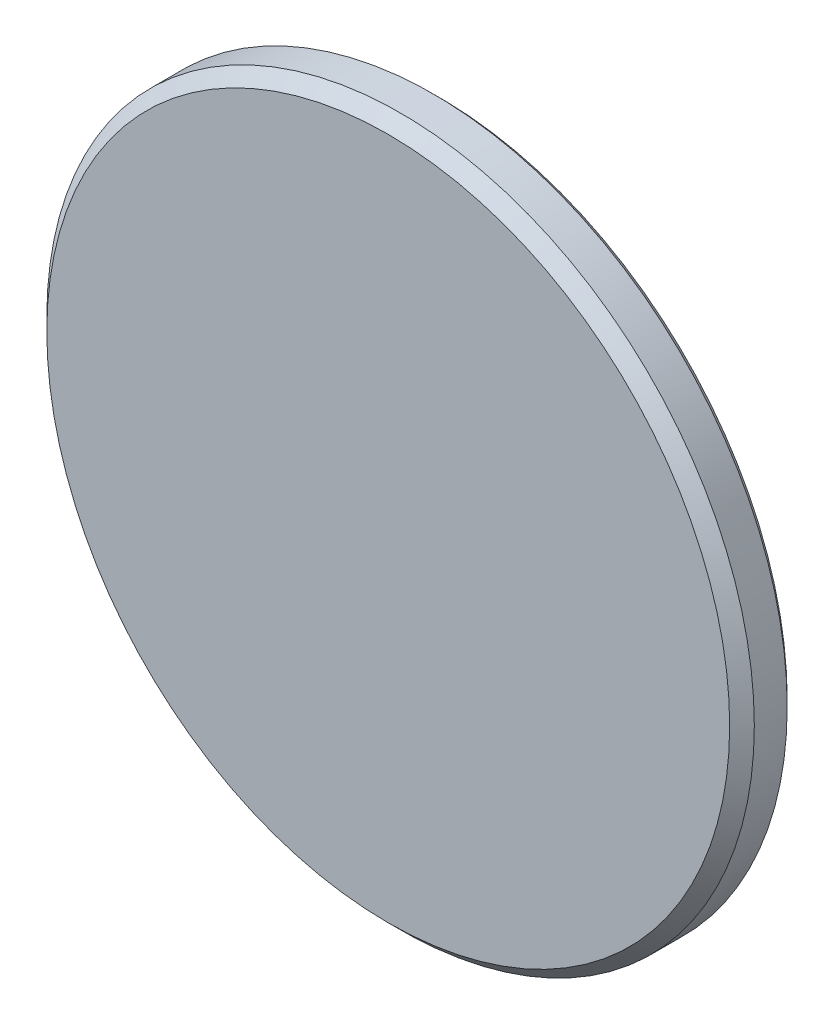
from build123d import *


with BuildPart() as part:
    # Sketch1 → Revolve1 (revolve)
    with BuildSketch(Plane(origin=(0, 0, 0), x_dir=(1, 0, 0), z_dir=(0, 1, 0))):
        Polygon((21.4884, 0), (0, 0), (0, -3.175), (21.1074, -3.175), (21.8694, -2.413), (21.8694, -0.381), align=None)
    revolve(axis=Axis((0, 0, 0), (0, 0, 1)))


solid = part.part
